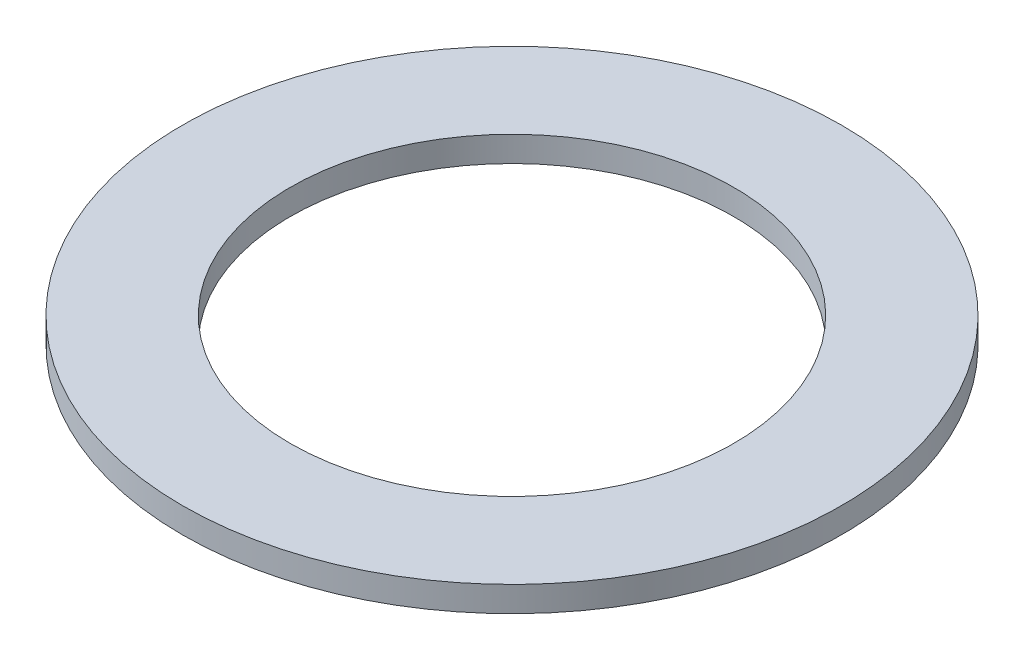
from build123d import *

# Parameters (mm, degrees)
SKETCH1_R           = 26
SKETCH1_R_2         = 17.5
BOSS_EXTRUDE1_DEPTH = 2


with BuildPart() as part:
    # Sketch1 → Boss-Extrude1 (new body)
    with BuildSketch(Plane(origin=(0, 0, 0), x_dir=(1, 0, 0), z_dir=(0, 1, 0))):
        Circle(SKETCH1_R)
        Circle(SKETCH1_R_2, mode=Mode.SUBTRACT)
    extrude(amount=BOSS_EXTRUDE1_DEPTH)


solid = part.part
